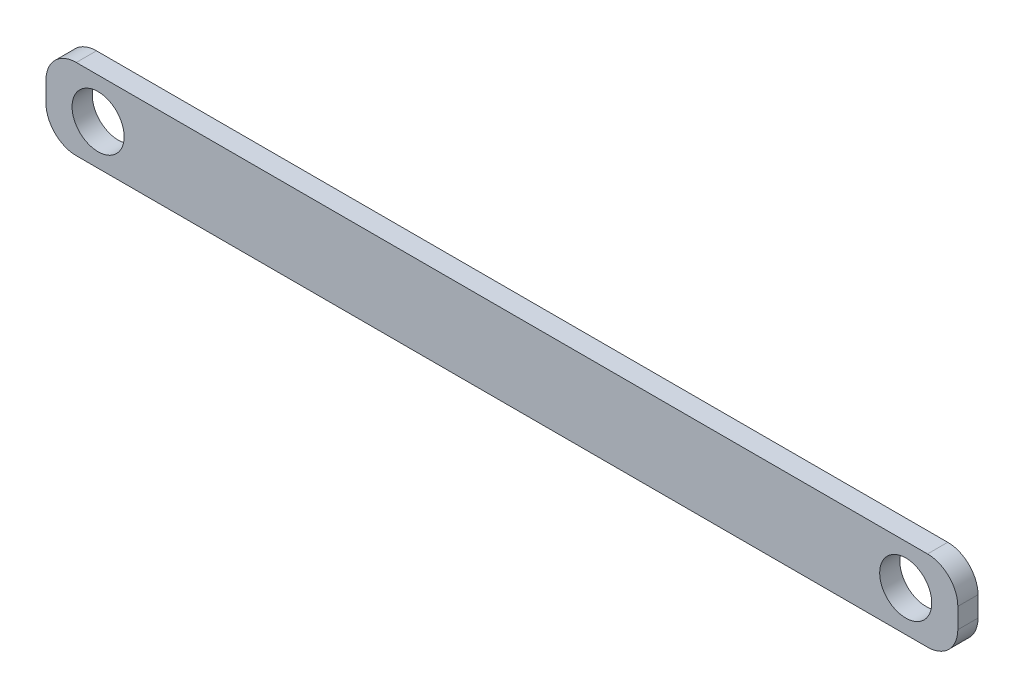
from build123d import *

# Parameters (mm, degrees)
SKETCH1_W           = 225.8
SKETCH1_H           = 20
SKETCH1_R           = 6.45
BOSS_EXTRUDE1_DEPTH = 5
FILLET1_R           = 7.5


with BuildPart() as part:
    # Sketch1 → Boss-Extrude1 (new body)
    with BuildSketch(Plane.XY):
        Rectangle(SKETCH1_W, SKETCH1_H)
        with Locations((-100, 0)):
            Circle(SKETCH1_R, mode=Mode.SUBTRACT)
        with Locations((100, 0)):
            Circle(SKETCH1_R, mode=Mode.SUBTRACT)
    extrude(amount=BOSS_EXTRUDE1_DEPTH)

    # Fillet1
    fillet1_edges = [part.edges().sort_by_distance(p)[0] for p in [
        (-112.9, 10, 2.5),
        (112.9, 10, 2.5),
        (112.9, -10, 2.5),
        (-112.9, -10, 2.5),
    ]]
    fillet(fillet1_edges, radius=FILLET1_R)


solid = part.part
